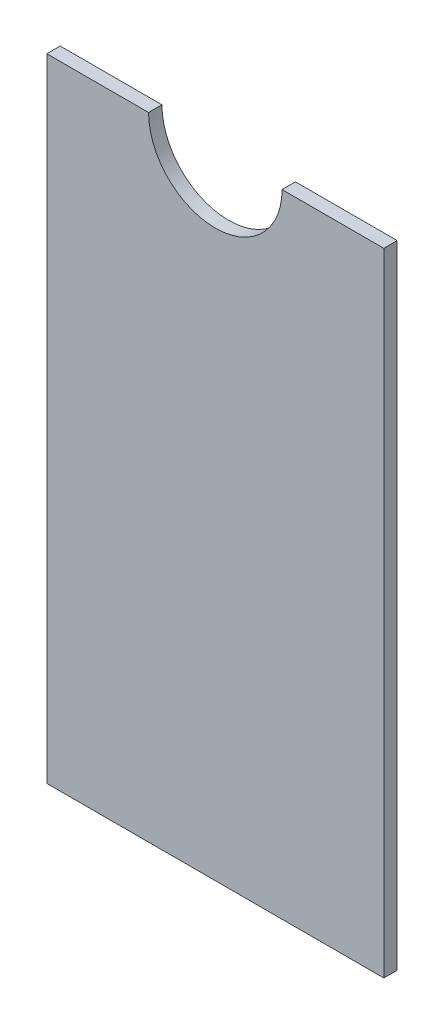
from build123d import *

# Parameters (mm, degrees)
BOSS_EXTRUDE1_DEPTH = 3.175


with BuildPart() as part:
    # Sketch1 → Boss-Extrude1 (new body)
    with BuildSketch(Plane.XY):
        with BuildLine():
            Line((15.85, 75), (40, 75))
            Line((40, 75), (40, -75))
            Line((40, -75), (-40, -75))
            Line((-40, -75), (-40, 75))
            Line((-40, 75), (-15.85, 75))
            ThreePointArc((-15.85, 75), (0, 59.15), (15.85, 75))
        make_face()
    extrude(amount=BOSS_EXTRUDE1_DEPTH)


solid = part.part
